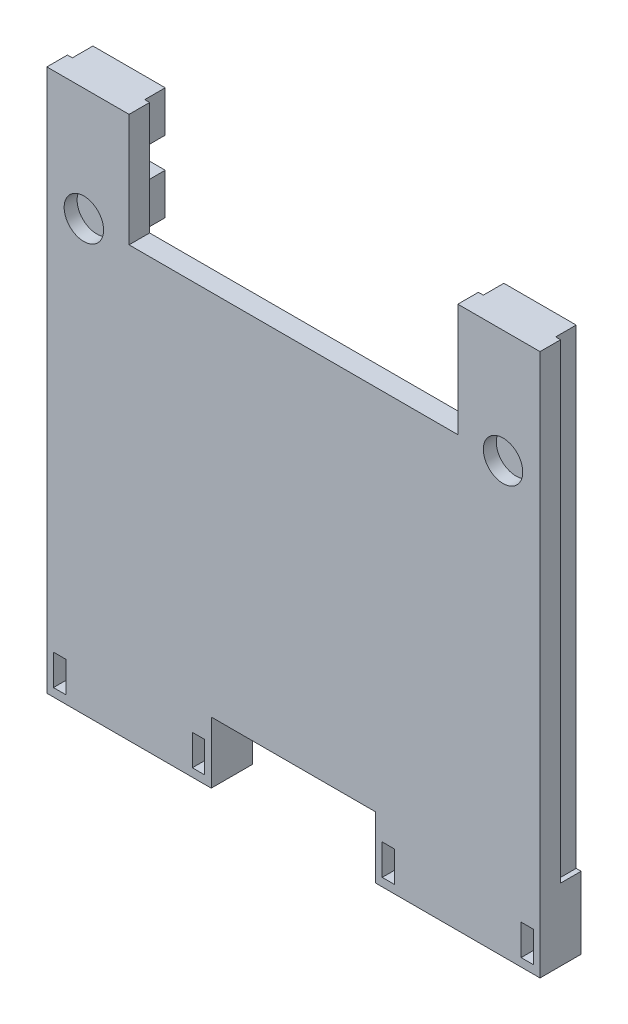
from build123d import *

# Parameters (mm, degrees)
BASE_DEPTH              = 3.175
SECOND_LAYER_DEPTH      = 3.175
SKETCH6_R               = 3.048
MAGNET_HOLDER_DEPTH     = 2
SKETCH7_W               = 1.905
SKETCH7_H               = 4.74726
SMALL_MAGNETS_CUT_DEPTH = 6.35


with BuildPart() as part:
    # Sketch1 → base (new body)
    with BuildSketch(Plane.XY):
        Polygon((88.9, -120.65), (88.9, -36.83), (76.2, -36.83), (76.2, -54.2925), (25.4, -54.2925), (25.4, -36.83), (12.7, -36.83), (12.7, -120.65), (38.1, -120.65), (38.1, -111.125), (63.5, -111.125), (63.5, -120.65), align=None)
    extrude(amount=-BASE_DEPTH)

    # Sketch2 → second layer (add)
    with BuildSketch(Plane(origin=(0, 0, -3.175), x_dir=(-1, 0, 0), z_dir=(0, 0, -1))):
        Polygon((-88.9, -120.65), (-88.9, -109.5375), (-88.138, -109.5375), (-88.138, -36.83), (-76.962, -36.83), (-76.962, -43.18), (-85.344, -43.18), (-85.344, -47.863125), (-76.962, -47.863125), (-76.962, -54.213125), (-85.344, -54.213125), (-85.344, -58.89625), (-76.962, -58.89625), (-76.962, -65.24625), (-85.344, -65.24625), (-85.344, -69.929375), (-76.962, -69.929375), (-76.962, -76.279375), (-85.344, -76.279375), (-85.344, -80.9625), (-76.962, -80.9625), (-76.962, -87.3125), (-85.344, -87.3125), (-85.344, -109.5375), (-16.256, -109.5375), (-16.256, -87.3125), (-24.638, -87.3125), (-24.638, -80.9625), (-16.256, -80.9625), (-16.256, -76.279375), (-24.638, -76.279375), (-24.638, -69.929375), (-16.256, -69.929375), (-16.256, -65.24625), (-24.638, -65.24625), (-24.638, -58.89625), (-16.256, -58.89625), (-16.256, -54.213125), (-24.638, -54.213125), (-24.638, -47.863125), (-16.256, -47.863125), (-16.256, -43.18), (-24.638, -43.18), (-24.638, -36.83), (-13.462, -36.83), (-13.462, -109.5375), (-12.7, -109.5375), (-12.7, -120.65), (-38.1, -120.65), (-38.1, -111.125), (-63.5, -111.125), (-63.5, -120.65), align=None)
    extrude(amount=SECOND_LAYER_DEPTH)

    # Sketch6 → magnet holder (cut)
    with BuildSketch(Plane.XY):
        with Locations((18.415, -54.2925)):
            Circle(SKETCH6_R)
        with Locations(Location((83.185, -54.2925, 0), (0, 0, 180))):  # turned: the seam where the file's is
            Circle(SKETCH6_R)
    extrude(amount=-MAGNET_HOLDER_DEPTH, mode=Mode.SUBTRACT)

    # Sketch7 → small magnets cut (cut)
    with BuildSketch(Plane.XY):
        with Locations((14.6685, -117.00637)):
            Rectangle(SKETCH7_W, SKETCH7_H)
        with Locations((36.1315, -117.00637)):
            Rectangle(SKETCH7_W, SKETCH7_H)
        with Locations((65.4685, -117.00637)):
            Rectangle(SKETCH7_W, SKETCH7_H)
        with Locations((86.9315, -117.00637)):
            Rectangle(SKETCH7_W, SKETCH7_H)
    extrude(amount=-SMALL_MAGNETS_CUT_DEPTH, mode=Mode.SUBTRACT)


solid = part.part
